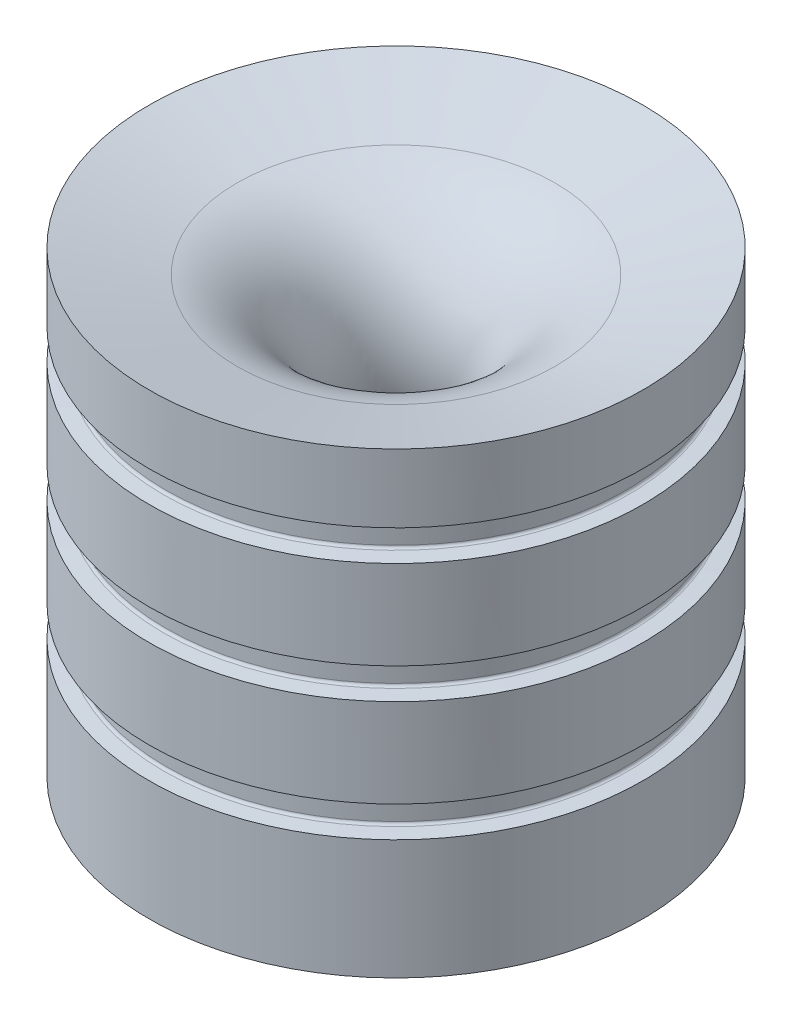
from build123d import *

# Parameters (mm, degrees)
LPATTERN1_COUNT = 3
LPATTERN1_PITCH = 20


with BuildPart() as part:
    # Sketch1 → Revolve1 (revolve)
    with BuildSketch(Plane.XY):
        with BuildLine():
            Line((41.275, 76.590797617), (41.275, 0))
            Line((41.275, 0), (23.27236431, 0))
            Line((23.27236431, 0), (11.024631822, 45.709159924))
            ThreePointArc((11.024631822, 45.709159924), (13.222441117, 62.403178916), (26.580981008, 72.653547095))
            Line((26.580981008, 72.653547095), (41.275, 76.590797617))
        make_face()
    revolve(axis=Axis((0, 11.203886574, 0), (0, 1, 0)))

    # Sketch3 → Groove for AS 568-234, O-Ring1 (revolve, cut)
    with BuildSketch(Plane(origin=(0, 11.203886574, 0), x_dir=(0, 0, -1), z_dir=(-1, 0, 0))):
        with BuildLine():
            Line((38.861359272, -9.01505737), (41.3639, -8.796113426))
            Line((41.3639, -8.796113426), (41.3639, -13.983801313))
            Line((41.3639, -13.983801313), (38.861359272, -13.76485737))
            ThreePointArc((38.861359272, -13.76485737), (38.572380224, -13.622348674), (38.4556, -13.322048826))
            Line((38.4556, -13.322048826), (38.4556, -9.457865913))
            ThreePointArc((38.4556, -9.457865913), (38.572380224, -9.157566066), (38.861359272, -9.01505737))
        make_face()
    groove_for_as_568_234_o_ring1 = revolve(axis=Axis((0, -38.796113426, 0), (0, 1, 0)), mode=Mode.SUBTRACT)

    # LPattern1: Groove for AS 568-234, O-Ring1 ×3
    with Locations(*[(0, i * LPATTERN1_PITCH, 0) for i in range(1, LPATTERN1_COUNT)]):
        add(groove_for_as_568_234_o_ring1, mode=Mode.SUBTRACT)


solid = part.part
